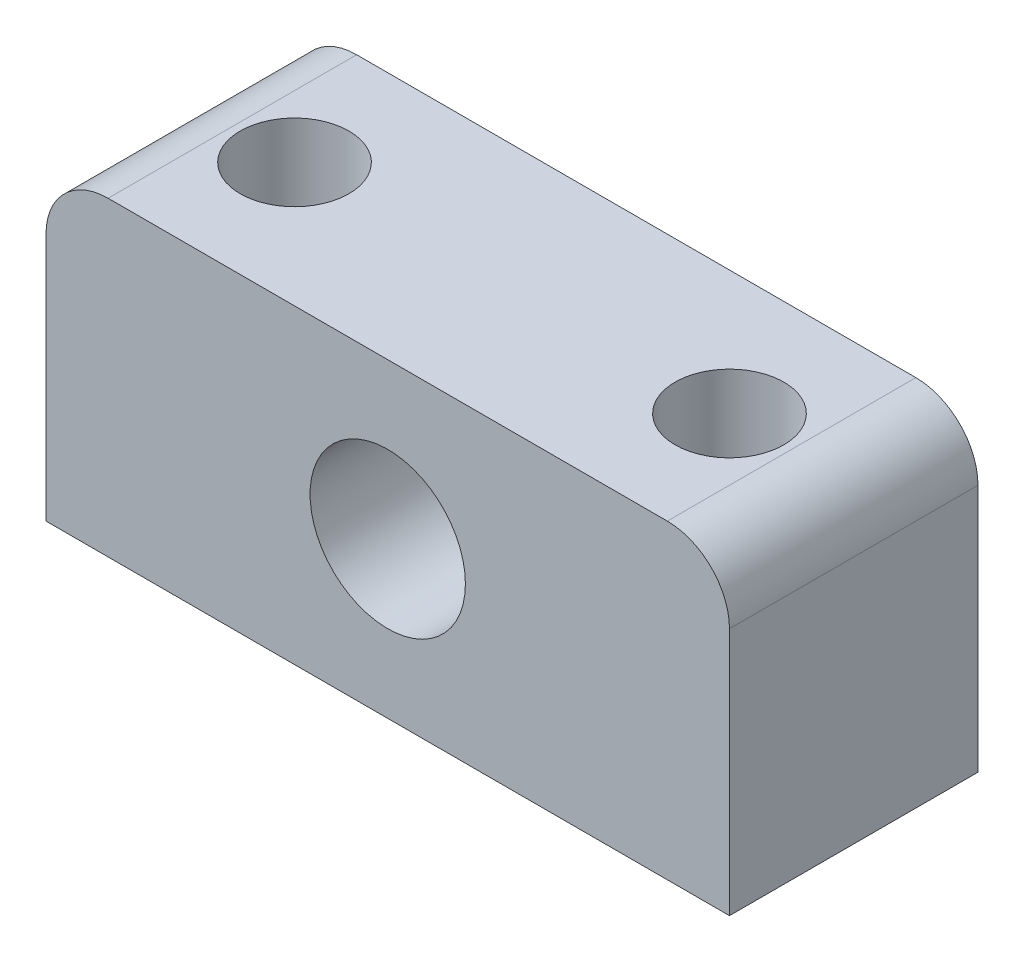
from build123d import *

# Parameters (mm, degrees)
SKETCH_1_W          = 22
SKETCH_1_H          = 10
SKETCH_1_R          = 2.5
EXTRUDE_1_DEPTH     = 4
SKETCH_3_R          = 1.75
CUT_EXTRUDE_1_DEPTH = 11
FILLET_1_R          = 2


with BuildPart() as part:
    # ｽｹｯﾁ1 → ﾎﾞｽ - 押し出し1 (new body, symmetric)
    with BuildSketch(Plane.XY):
        Rectangle(SKETCH_1_W, SKETCH_1_H)
        Circle(SKETCH_1_R, mode=Mode.SUBTRACT)
    extrude(amount=EXTRUDE_1_DEPTH, both=True)

    # ｽｹｯﾁ3 → ｶｯﾄ - 押し出し1 (cut, through all)
    with BuildSketch(Plane(origin=(0, 5, 0), x_dir=(1, 0, 0), z_dir=(0, 1, 0))):
        with Locations((7, 0)):
            Circle(SKETCH_3_R)
        with Locations((-7, 0)):
            Circle(SKETCH_3_R)
    extrude(amount=-CUT_EXTRUDE_1_DEPTH, mode=Mode.SUBTRACT)

    # ﾌｨﾚｯﾄ1
    fillet_1_edges = [part.edges().sort_by_distance(p)[0] for p in [
        (-11, 5, 0),
        (11, 5, 0),
    ]]
    fillet(fillet_1_edges, radius=FILLET_1_R)


solid = part.part
